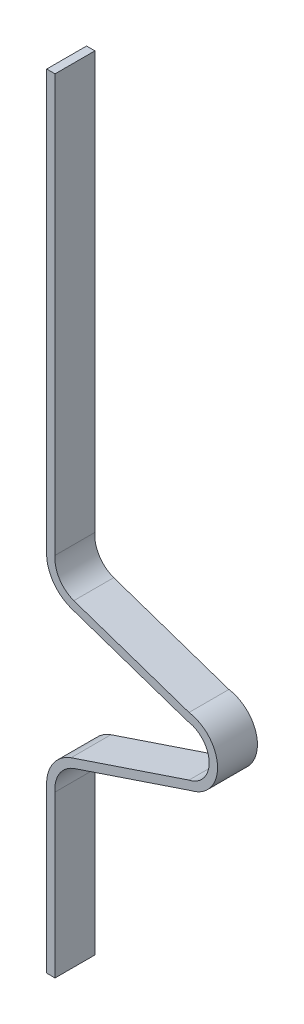
from build123d import *

# Parameters (mm, degrees)
BOSS_EXTRUDE1_DEPTH = 6.2
SKETCH2_W           = 22.942955783
SKETCH2_H           = 33.63345143
CUT_EXTRUDE1_DEPTH  = 10
SKETCH3_W           = 6.2
SKETCH3_H           = 21.335576668
CUT_EXTRUDE2_DEPTH  = 10
SKETCH4_W           = 6.2
SKETCH4_H           = 34.092468675
CUT_EXTRUDE3_DEPTH  = 10


with BuildPart() as part:
    # Sketch1 → Boss-Extrude1 (new body)
    with BuildSketch(Plane.XY):
        with BuildLine():
            Line((5.938584497, 132.670572888), (23.853053602, 126.575547243))
            ThreePointArc((23.853053602, 126.575547243), (28.280634989, 121.537232872), (24.198169049, 116.215432378))
            Line((24.198169049, 116.215432378), (5.937692527, 110.081409755))
            ThreePointArc((5.937692527, 110.081409755), (3.69123593, 108.257803943), (3.019475766, 105.443404596))
            Line((3.019475766, 105.443404596), (3.019475766, 19.274702795))
            Line((3.019475766, 19.274702795), (1.719475766, 19.274702795))
            Line((1.719475766, 19.274702795), (1.719475766, 105.386747909))
            ThreePointArc((1.719475766, 105.386747909), (2.613791193, 108.9861771), (5.506131352, 111.307827159))
            Line((5.506131352, 111.307827159), (23.847136202, 117.468900696))
            ThreePointArc((23.847136202, 117.468900696), (26.980585626, 121.515340919), (23.543843406, 125.30756806))
            Line((23.543843406, 125.30756806), (5.504633735, 131.445034089))
            ThreePointArc((5.504633735, 131.445034089), (2.6133616, 133.766807499), (1.719475766, 137.365564846))
            Line((1.719475766, 137.365564846), (1.719475766, 223.477609961))
            Line((1.719475766, 223.477609961), (3.019475766, 223.477609961))
            Line((3.019475766, 223.477609961), (3.019475766, 137.30890816))
            ThreePointArc((3.019475766, 137.30890816), (3.691489205, 134.494106323), (5.938584497, 132.670572888))
        make_face()
    extrude(amount=-BOSS_EXTRUDE1_DEPTH)

    # Sketch2 → Cut-Extrude1 (cut)
    with BuildSketch(Plane.ZY.offset(-1.719475766)):
        with Locations((-7.178599834, 29.49715685)):
            Rectangle(SKETCH2_W, SKETCH2_H)
    extrude(amount=-CUT_EXTRUDE1_DEPTH, mode=Mode.SUBTRACT)

    # Sketch3 → Cut-Extrude2 (cut)
    with BuildSketch(Plane(origin=(3.019475766, 0, 0), x_dir=(0, 0, -1), z_dir=(1, 0, 0))):
        with Locations((3.1, 212.809821627)):
            Rectangle(SKETCH3_W, SKETCH3_H)
    extrude(amount=-CUT_EXTRUDE2_DEPTH, mode=Mode.SUBTRACT)

    # Sketch4 → Cut-Extrude3 (cut)
    with BuildSketch(Plane(origin=(3.019475766, 0, 0), x_dir=(0, 0, -1), z_dir=(1, 0, 0))):
        with Locations((3.1, 63.360116903)):
            Rectangle(SKETCH4_W, SKETCH4_H)
    extrude(amount=-CUT_EXTRUDE3_DEPTH, mode=Mode.SUBTRACT)


solid = part.part
